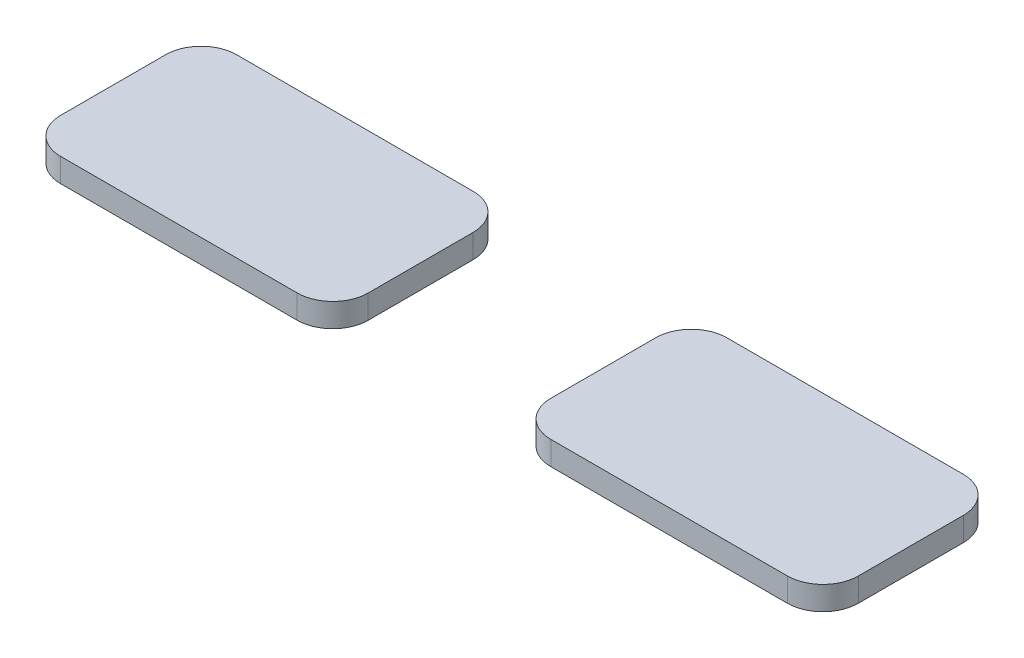
from build123d import *

# Parameters (mm, degrees)
EXTRUDE_1_DEPTH   = 2
EXTRUDE_1_2_DEPTH = 2


with BuildPart() as part:
    # 草图1 → 凸台-拉伸1 (new body)
    with BuildSketch(Plane(origin=(0, 0, 0), x_dir=(1, 0, 0), z_dir=(0, 1, 0))):
        with BuildLine():
            Line((-9.995, -7.435), (9.995, -7.435))
            ThreePointArc((9.995, -7.435), (12.116320344, -6.556320344), (12.995, -4.435))
            Line((12.995, -4.435), (12.995, 4.435))
            ThreePointArc((12.995, 4.435), (12.116320344, 6.556320344), (9.995, 7.435))
            Line((9.995, 7.435), (-9.995, 7.435))
            ThreePointArc((-9.995, 7.435), (-12.116320344, 6.556320344), (-12.995, 4.435))
            Line((-12.995, 4.435), (-12.995, -4.435))
            ThreePointArc((-12.995, -4.435), (-12.116320344, -6.556320344), (-9.995, -7.435))
        make_face()
    extrude(amount=EXTRUDE_1_DEPTH)


with BuildPart() as body_2:
    # 草图1 → Extrude 1 2 (new body)
    with BuildSketch(Plane(origin=(0, 0, 0), x_dir=(1, 0, 0), z_dir=(0, 1, 0))):
        with BuildLine():
            Line((28.414655294, -4.435), (28.414655294, 4.435))
            ThreePointArc((28.414655294, 4.435), (29.29333495, 6.556320344), (31.414655294, 7.435))
            Line((31.414655294, 7.435), (51.404655294, 7.435))
            ThreePointArc((51.404655294, 7.435), (53.525975637, 6.556320344), (54.404655294, 4.435))
            Line((54.404655294, 4.435), (54.404655294, -4.435))
            ThreePointArc((54.404655294, -4.435), (53.525975637, -6.556320344), (51.404655294, -7.435))
            Line((51.404655294, -7.435), (31.414655294, -7.435))
            ThreePointArc((31.414655294, -7.435), (29.29333495, -6.556320344), (28.414655294, -4.435))
        make_face()
    extrude(amount=EXTRUDE_1_2_DEPTH)


solid = Compound([part.part, body_2.part])
